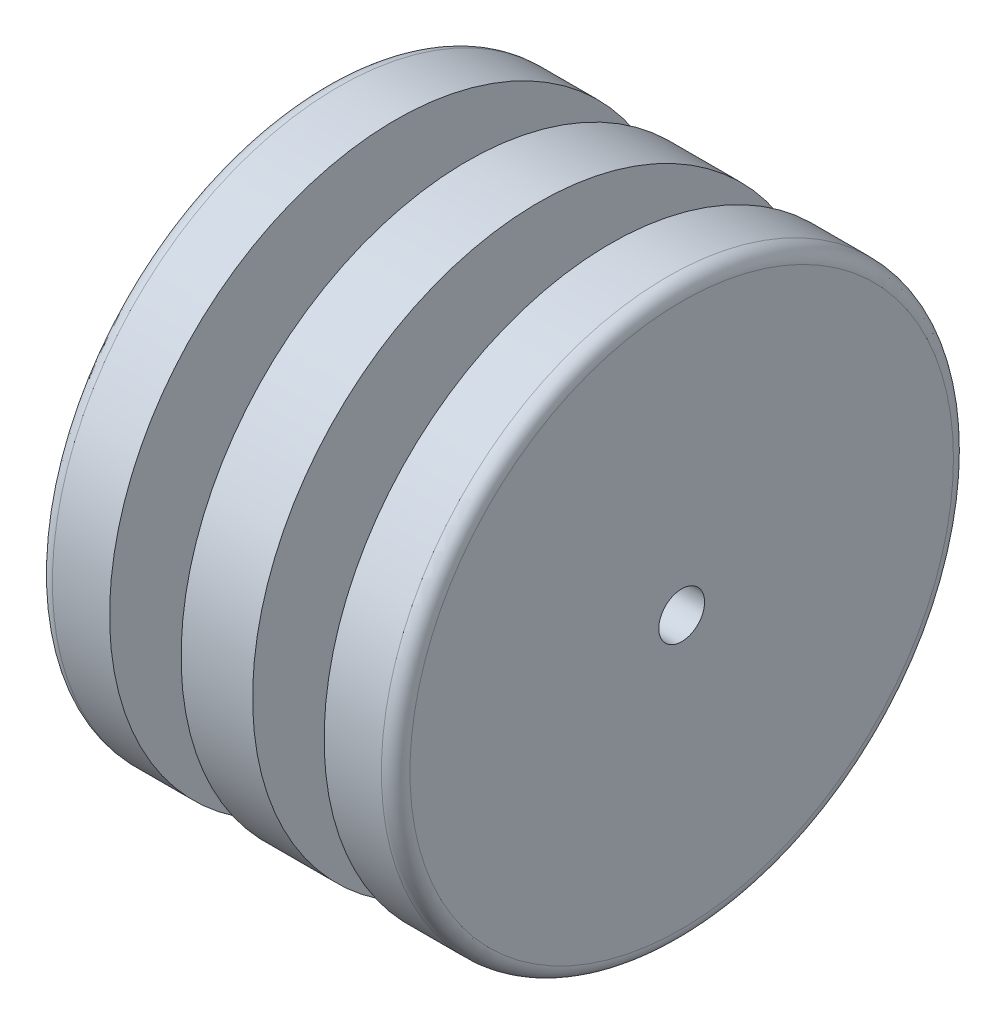
from build123d import *

# Parameters (mm, degrees)
SKETCH1_R           = 20
BOSS_EXTRUDE1_DEPTH = 5
SKETCH2_R           = 12.5
BOSS_EXTRUDE2_DEPTH = 5
SKETCH3_R           = 20
BOSS_EXTRUDE3_DEPTH = 5
SKETCH4_R           = 12.5
BOSS_EXTRUDE4_DEPTH = 5
SKETCH5_R           = 20
BOSS_EXTRUDE5_DEPTH = 5
FILLET1_R           = 1
SKETCH6_R           = 1.6
CUT_EXTRUDE1_DEPTH  = 25


with BuildPart() as part:
    # Sketch1 → Boss-Extrude1 (new body)
    with BuildSketch(Plane(origin=(0, 0, 0), x_dir=(0, 0, -1), z_dir=(1, 0, 0))):
        Circle(SKETCH1_R)
    extrude(amount=BOSS_EXTRUDE1_DEPTH)

    # Sketch2 → Boss-Extrude2 (add)
    with BuildSketch(Plane(origin=(5, 0, 0), x_dir=(0, 0, -1), z_dir=(1, 0, 0))):
        Circle(SKETCH2_R)
    extrude(amount=BOSS_EXTRUDE2_DEPTH)

    # Sketch3 → Boss-Extrude3 (add)
    with BuildSketch(Plane(origin=(10, 0, 0), x_dir=(0, 0, -1), z_dir=(1, 0, 0))):
        Circle(SKETCH3_R)
    extrude(amount=BOSS_EXTRUDE3_DEPTH)

    # Sketch4 → Boss-Extrude4 (add)
    with BuildSketch(Plane(origin=(15, 0, 0), x_dir=(0, 0, -1), z_dir=(1, 0, 0))):
        Circle(SKETCH4_R)
    extrude(amount=BOSS_EXTRUDE4_DEPTH)

    # Sketch5 → Boss-Extrude5 (add)
    with BuildSketch(Plane(origin=(20, 0, 0), x_dir=(0, 0, -1), z_dir=(1, 0, 0))):
        Circle(SKETCH5_R)
    extrude(amount=BOSS_EXTRUDE5_DEPTH)

    # Fillet1
    fillet1_edges = [part.edges().sort_by_distance(p)[0] for p in [
        (25, 0, 20),
        (0, 0, 20),
    ]]
    fillet(fillet1_edges, radius=FILLET1_R)

    # Sketch6 → Cut-Extrude1 (cut)
    with BuildSketch(Plane(origin=(25, 0, 0), x_dir=(0, 0, -1), z_dir=(1, 0, 0))):
        Circle(SKETCH6_R)
    extrude(amount=-CUT_EXTRUDE1_DEPTH, mode=Mode.SUBTRACT)


solid = part.part
